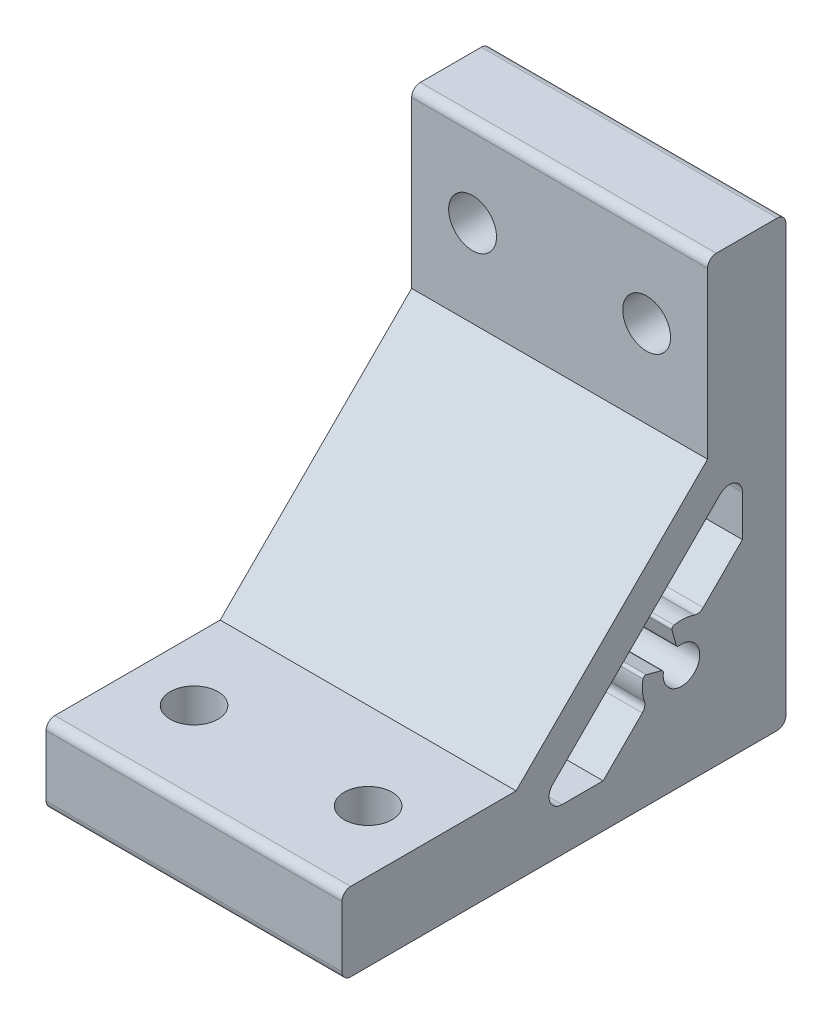
from build123d import *

# Parameters (mm, degrees)
BOSS_EXTRUDE1_DEPTH      = 17
BOSS_EXTRUDE1_DEPTH_BACK = 17
SKETCH2_R                = 2.75
CUT_EXTRUDE1_DEPTH       = 9
SKETCH3_R                = 2.75
CUT_EXTRUDE2_DEPTH       = 9
SKETCH4_R                = 2.75
CUT_EXTRUDE3_DEPTH       = 9
SKETCH5_R                = 2.75
CUT_EXTRUDE4_DEPTH       = 9


with BuildPart() as part:
    # Sketch1 → Boss-Extrude1 (new, two sides: drawn at the far end of the back side and taken through both)
    with BuildSketch(Plane(origin=(0, 0, 0), x_dir=(0, 0, -1), z_dir=(1, 0, 0)).offset(-BOSS_EXTRUDE1_DEPTH_BACK)):
        with BuildLine():
            Line((-50, 0), (-1, 0))
            ThreePointArc((-1, 0), (-0.292893219, 0.292893219), (0, 1))
            Line((0, 1), (0, 50))
            ThreePointArc((0, 50), (-0.292893219, 50.707106781), (-1, 51))
            Line((-1, 51), (-8, 51))
            ThreePointArc((-8, 51), (-8.707106781, 50.707106781), (-9, 50))
            Line((-9, 50), (-9, 31))
            Line((-9, 31), (-31, 9))
            Line((-31, 9), (-50, 9))
            ThreePointArc((-50, 9), (-50.707106781, 8.707106781), (-51, 8))
            Line((-51, 8), (-51, 1))
            ThreePointArc((-51, 1), (-50.707106781, 0.292893219), (-50, 0))
        make_face()
        with BuildLine():
            Line((-25.721825407, 5), (-20.999285733, 5))
            Line((-20.999285733, 5), (-16.494036438, 9.505249294))
            ThreePointArc((-16.494036438, 9.505249294), (-16.226979866, 9.987090789), (-16.255625497, 10.537245192))
            ThreePointArc((-16.255625497, 10.537245192), (-16.488859314, 11.683547702), (-16.418755424, 12.851234691))
            ThreePointArc((-16.418755424, 12.851234691), (-16.283360667, 13.048766752), (-16.046526031, 13.084263382))
            Line((-16.046526031, 13.084263382), (-14.300039569, 12.616293745))
            ThreePointArc((-14.300039569, 12.616293745), (-14.127781033, 12.492491496), (-14.080474622, 12.285701498))
            ThreePointArc((-14.080474622, 12.285701498), (-10.515075745, 10.515075774), (-12.285701539, 14.080474617))
            ThreePointArc((-12.285701539, 14.080474617), (-12.492491514, 14.127781045), (-12.616293745, 14.300039569))
            Line((-12.616293745, 14.300039569), (-13.084263382, 16.046526031))
            ThreePointArc((-13.084263382, 16.046526031), (-13.048766728, 16.283360705), (-12.851234602, 16.418755442))
            ThreePointArc((-12.851234602, 16.418755442), (-11.683774102, 16.488875269), (-10.537674556, 16.255773055))
            ThreePointArc((-10.537674556, 16.255773055), (-9.987311976, 16.226928716), (-9.505249294, 16.494036438))
            Line((-9.505249294, 16.494036438), (-5, 20.999285733))
            Line((-5, 20.999285733), (-5, 25.721825407))
            ThreePointArc((-5, 25.721825407), (-5.925974851, 27.107644706), (-7.560660172, 26.782485579))
            Line((-7.560660172, 26.782485579), (-26.782485579, 7.560660172))
            ThreePointArc((-26.782485579, 7.560660172), (-27.107644706, 5.925974851), (-25.721825407, 5))
        make_face(mode=Mode.SUBTRACT)
    extrude(amount=BOSS_EXTRUDE1_DEPTH + BOSS_EXTRUDE1_DEPTH_BACK)

    # Sketch2 → Cut-Extrude1 (cut)
    with BuildSketch(Plane(origin=(0, 0, 0), x_dir=(-1, 0, 0), z_dir=(0, 1, 0))):
        with Locations((10, 41)):
            Circle(SKETCH2_R)
    extrude(amount=CUT_EXTRUDE1_DEPTH, mode=Mode.SUBTRACT)

    # Sketch3 → Cut-Extrude2 (cut)
    with BuildSketch(Plane(origin=(0, 0, 0), x_dir=(-1, 0, 0), z_dir=(0, 1, 0))):
        with Locations((-10, 41)):
            Circle(SKETCH3_R)
    extrude(amount=CUT_EXTRUDE2_DEPTH, mode=Mode.SUBTRACT)

    # Sketch4 → Cut-Extrude3 (cut)
    with BuildSketch(Plane.XY):
        with Locations((-10, 41)):
            Circle(SKETCH4_R)
    extrude(amount=CUT_EXTRUDE3_DEPTH, mode=Mode.SUBTRACT)

    # Sketch5 → Cut-Extrude4 (cut)
    with BuildSketch(Plane.XY):
        with Locations((10, 41)):
            Circle(SKETCH5_R)
    extrude(amount=CUT_EXTRUDE4_DEPTH, mode=Mode.SUBTRACT)


solid = part.part
